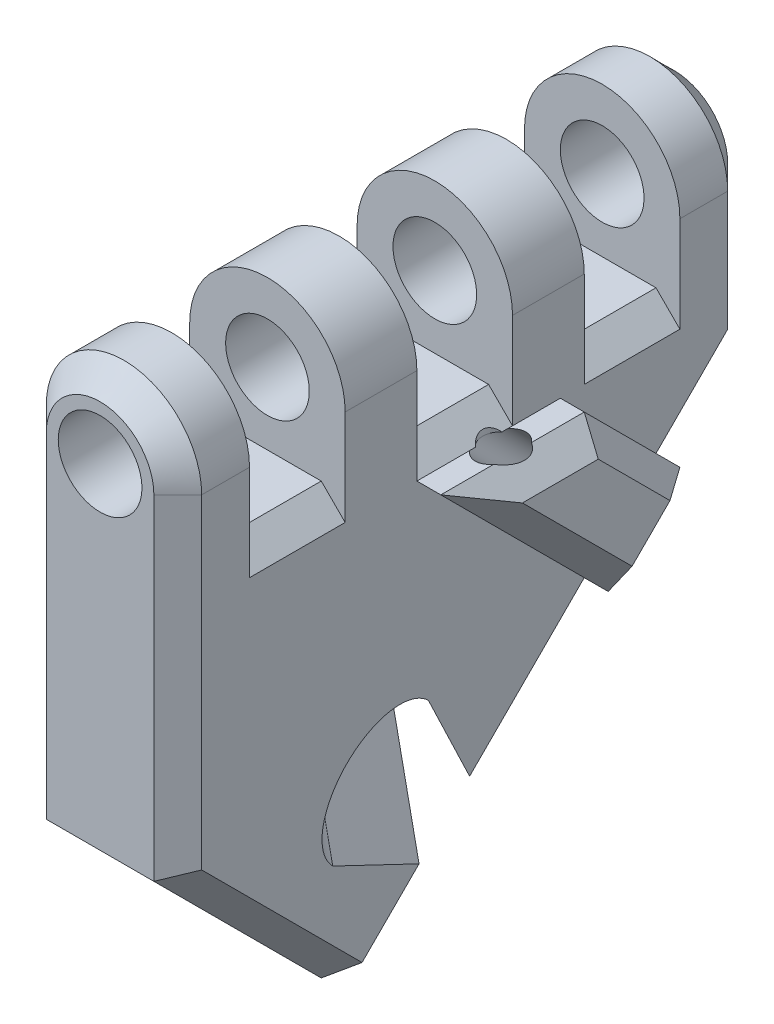
from build123d import *

# Parameters (mm, degrees)
BOSS_EXTRUDE1_DEPTH      = 24
SKETCH2_R                = 1.75
CUT_EXTRUDE1_DEPTH       = 24
SKETCH3_W                = 4
SKETCH3_H                = 7
CUT_EXTRUDE2_DEPTH       = 6.5
CHAMFER1_SIZE            = 1
CUT_EXTRUDE4_REACH       = 39.447
CUT_EXTRUDE5_DEPTH       = 38.446629
CHAMFER3_SIZE            = 1
CUT_EXTRUDE10_DEPTH      = 13
CUT_EXTRUDE10_DEPTH_BACK = 13
SKETCH11_W               = 4
SKETCH11_H               = 10
BOSS_EXTRUDE3_DEPTH      = 2
CHAMFER4_SIZE            = 1
SKETCH12_R               = 0.75
CUT_EXTRUDE6_DEPTH       = 2
CUT_EXTRUDE6_DEPTH_BACK  = 15
BOSS_EXTRUDE6_DEPTH      = 2
CHAMFER6_SIZE            = 1
CUT_EXTRUDE11_REACH      = 34.628
SKETCH19_R               = 0.75
SKETCH20_R               = 0.75
CUT_EXTRUDE12_DEPTH      = 1


with BuildPart() as part:
    # Sketch1 → Boss-Extrude1 (new body)
    with BuildSketch(Plane.XY):
        with BuildLine():
            Line((-3.25, 0), (-3.25, -28))
            Line((-3.25, -28), (3.25, -28))
            Line((3.25, -28), (3.25, 0))
            ThreePointArc((3.25, 0), (0, 3.25), (-3.25, 0))
        make_face()
    extrude(amount=BOSS_EXTRUDE1_DEPTH)

    # Sketch2 → Cut-Extrude1 (cut)
    with BuildSketch(Plane(origin=(0, 0, 0), x_dir=(-1, 0, 0), z_dir=(0, 0, -1))):
        Circle(SKETCH2_R)
    extrude(amount=-CUT_EXTRUDE1_DEPTH, mode=Mode.SUBTRACT)

    # Sketch3 → Cut-Extrude2 (cut)
    with BuildSketch(Plane.ZY.offset(3.25)):
        with Locations((5, 0.5)):
            Rectangle(SKETCH3_W, SKETCH3_H)
        with Locations((19, 0.5)):
            Rectangle(SKETCH3_W, SKETCH3_H)
        with Locations((12, 0.5)):
            Rectangle(SKETCH3_W, SKETCH3_H)
    extrude(amount=-CUT_EXTRUDE2_DEPTH, mode=Mode.SUBTRACT)

    # Chamfer1
    chamfer1_edges = [part.edges().sort_by_distance(p)[0] for p in [
        (3.25, -3, 5),
        (-3.25, -3, 5),
        (3.25, -3, 19),
        (-3.25, -3, 19),
        (3.25, -3, 12),
        (-3.25, -3, 12),
    ]]
    chamfer(chamfer1_edges, length=CHAMFER1_SIZE)

    # Sketch7 → Cut-Extrude4 (cut, up to next)
    with BuildSketch(Plane.ZY.offset(3.25), mode=Mode.PRIVATE) as cut_extrude4_sk1:
        Polygon((24, -28), (0, -4), (0, -28), align=None)
    cut_extrude4_tool1 = extrude(cut_extrude4_sk1.sketch, amount=-CUT_EXTRUDE4_REACH, mode=Mode.PRIVATE) & part.part
    add(cut_extrude4_tool1.solids().sort_by_distance((-3.25, -20, 8))[0], mode=Mode.SUBTRACT)

    # Sketch10 → Cut-Extrude5 (cut, through all)
    with BuildSketch(Plane(origin=(3.25, 0, 0), x_dir=(0, 0, -1), z_dir=(1, 0, 0))):
        Polygon((-24, -14), (-17, -21), (-24, -28), align=None)
    extrude(amount=-CUT_EXTRUDE5_DEPTH, mode=Mode.SUBTRACT)

    # Chamfer3
    chamfer3_edges = [part.edges().sort_by_distance(p)[0] for p in [
        (-3.25, -7, 24),
        (3.25, -2, 0),
        (3.25, -7, 24),
        (3.25, -17.5, 20.5),
        (-3.25, -17.5, 20.5),
        (-3.25, -2, 0),
        (0, 3.25, 0),
        (0, 3.25, 24),
    ]]
    chamfer(chamfer3_edges, length=CHAMFER3_SIZE)

    # Sketch18 → Cut-Extrude10 (cut, two sides)
    with BuildSketch(Plane(origin=(11.810029, -8.350951, 8.350951), x_dir=(-0.4082482904638629, 0.2886751345948129, 0.8660254037844388), z_dir=(-0.7071067811865475, 0.5000000000000001, -0.4999999999999999))) as cut_extrude10_sk:
        with BuildLine():
            ThreePointArc((6.229669, -8.809395), (6.383996, -10.861584), (8.267375, -11.691148))
            Line((8.267375, -11.691148), (9.17169, -11.339876))
            ThreePointArc((9.17169, -11.339876), (9.793137, -10.626285), (10.016989, -9.706883))
            ThreePointArc((10.016989, -9.706883), (8.936391, -7.930735), (6.862289, -8.07389))
            Line((6.862289, -8.07389), (6.229669, -8.809395))
        make_face()
        with BuildLine():
            Line((2.829335, -12.762736), (3.406685, -13.579233))
            Line((3.406685, -13.579233), (8.267375, -11.691148))
            ThreePointArc((8.267375, -11.691148), (6.383996, -10.861584), (6.229669, -8.809395))
            Line((6.229669, -8.809395), (2.829335, -12.762736))
        make_face()
    extrude(amount=CUT_EXTRUDE10_DEPTH, mode=Mode.SUBTRACT)
    extrude(cut_extrude10_sk.sketch, amount=-CUT_EXTRUDE10_DEPTH_BACK, mode=Mode.SUBTRACT)

    # Sketch11 → Boss-Extrude3 (add)
    with BuildSketch(Plane.ZY.offset(3.25)):
        with Locations((12, -9)):
            Rectangle(SKETCH11_W, SKETCH11_H)
    extrude(amount=BOSS_EXTRUDE3_DEPTH)

    # Chamfer4
    chamfer4_edges = [part.edges().sort_by_distance(p)[0] for p in [
        (-5.25, -9, 10),
        (-5.25, -14, 12),
        (-5.25, -9, 14),
        (-5.25, -4, 12),
    ]]
    chamfer(chamfer4_edges, length=CHAMFER4_SIZE)

    # Sketch12 → Cut-Extrude6 (cut, two sides)
    with BuildSketch(Plane(origin=(0, -4, 0), x_dir=(1, 0, 0), z_dir=(0, 1, 0))) as cut_extrude6_sk:
        with Locations(Location((-3.75, -12, 0), (0, 0, 48.189685))):
            Circle(SKETCH12_R)
    extrude(amount=CUT_EXTRUDE6_DEPTH, mode=Mode.SUBTRACT)
    extrude(cut_extrude6_sk.sketch, amount=-CUT_EXTRUDE6_DEPTH_BACK, mode=Mode.SUBTRACT)

    # Sketch14 → Boss-Extrude6 (add)
    with BuildSketch(Plane(origin=(3.25, 0, 0), x_dir=(0, 0, -1), z_dir=(1, 0, 0))):
        Polygon((-14, -4), (-7, -11), (-4, -8), (-8, -4), align=None)
    extrude(amount=BOSS_EXTRUDE6_DEPTH)

    # Chamfer6
    chamfer6_edges = [part.edges().sort_by_distance(p)[0] for p in [
        (5.25, -4, 11),
        (5.25, -9.5, 5.5),
        (5.25, -6, 6),
        (5.25, -7.5, 10.5),
    ]]
    chamfer(chamfer6_edges, length=CHAMFER6_SIZE)

    # Cut-Extrude11: up to this plane
    cut_extrude11_end = Plane(origin=(5.25, -4, 0), z_dir=(0, 1, 0))
    # Sketch19 → Cut-Extrude11 (cut, up to the surface)
    with BuildSketch(Plane(origin=(0, -2, -2), x_dir=(1, 0, 0), z_dir=(0, -0.7071067811865475, -0.7071067811865476)), mode=Mode.PRIVATE) as cut_extrude11_sk1:
        with Locations(Location((3.75, 10.606602, 0), (0, 0, 311.810315))):
            Circle(SKETCH19_R)
    cut_extrude11_tool1 = split(extrude(cut_extrude11_sk1.sketch, amount=-CUT_EXTRUDE11_REACH, mode=Mode.PRIVATE), bisect_by=cut_extrude11_end, keep=Keep.BOTH, mode=Mode.PRIVATE)
    add(cut_extrude11_tool1.solids().sort_by_distance((3.75, -9.5, 5.5))[0], mode=Mode.SUBTRACT)

    # Sketch20 → Cut-Extrude12 (cut)
    with BuildSketch(Plane(origin=(0, -4, 0), x_dir=(1, 0, 0), z_dir=(0, 1, 0))):
        with Locations((3.75, -11)):
            Circle(SKETCH20_R)
    extrude(amount=CUT_EXTRUDE12_DEPTH, mode=Mode.SUBTRACT)


solid = part.part
